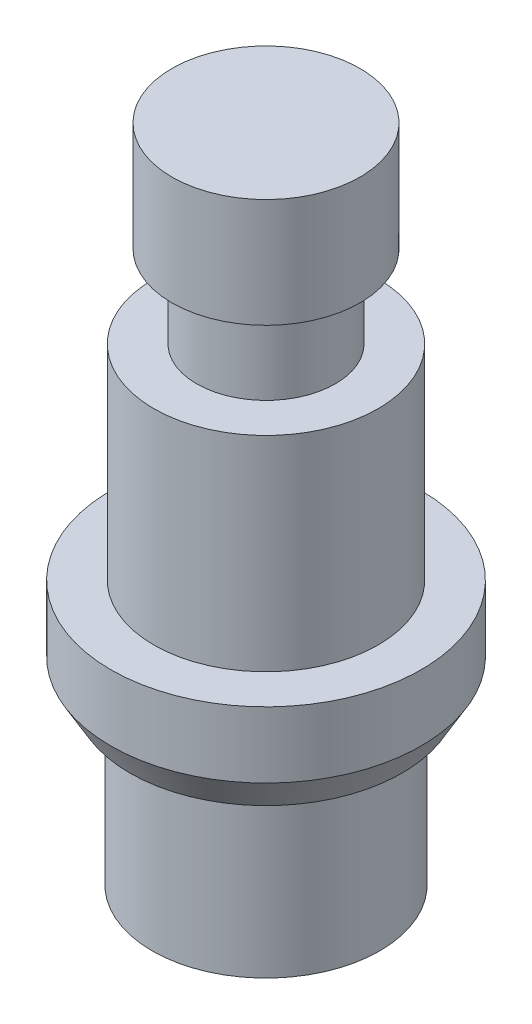
from build123d import *

# Parameters (mm, degrees)
SKETCH1_R           = 4.7
BOSS_EXTRUDE1_DEPTH = 20
SKETCH2_OUTSIDE_W   = 16.202
SKETCH2_OUTSIDE_H   = 16.202
SKETCH2_OUTSIDE_R   = 3.45
CUT_EXTRUDE1_DEPTH  = 5
SKETCH4_OUTSIDE_W   = 16.202
SKETCH4_OUTSIDE_H   = 16.202
SKETCH4_OUTSIDE_R   = 3.4
CUT_EXTRUDE2_DEPTH  = 12
SKETCH5_OUTSIDE_W   = 16.202
SKETCH5_OUTSIDE_H   = 16.202
SKETCH5_OUTSIDE_R   = 2.85
CUT_EXTRUDE3_DEPTH  = 3.3
SKETCH7_OUTSIDE_W   = 16.202
SKETCH7_OUTSIDE_H   = 16.202
SKETCH7_OUTSIDE_R   = 2.1
CUT_EXTRUDE4_DEPTH  = 2.5
CHAMFER1_SIZE       = 1
CHAMFER1_SIZE2      = 0.577350269


with BuildPart() as part:
    # Sketch1 → Boss-Extrude1 (new body)
    with BuildSketch(Plane(origin=(0, 0, 0), x_dir=(1, 0, 0), z_dir=(0, 1, 0))):
        Circle(SKETCH1_R)
    extrude(amount=BOSS_EXTRUDE1_DEPTH)

    # Sketch2 outside → Cut-Extrude1 (cut)
    with BuildSketch(Plane.XZ):
        Rectangle(SKETCH2_OUTSIDE_W, SKETCH2_OUTSIDE_H)
        Circle(SKETCH2_OUTSIDE_R, mode=Mode.SUBTRACT)
    extrude(amount=-CUT_EXTRUDE1_DEPTH, mode=Mode.SUBTRACT)

    # Sketch4 outside → Cut-Extrude2 (cut)
    with BuildSketch(Plane(origin=(0, 20, 0), x_dir=(1, 0, 0), z_dir=(0, 1, 0))):
        Rectangle(SKETCH4_OUTSIDE_W, SKETCH4_OUTSIDE_H)
        Circle(SKETCH4_OUTSIDE_R, mode=Mode.SUBTRACT)
    extrude(amount=-CUT_EXTRUDE2_DEPTH, mode=Mode.SUBTRACT)

    # Sketch5 outside → Cut-Extrude3 (cut)
    with BuildSketch(Plane(origin=(0, 20, 0), x_dir=(1, 0, 0), z_dir=(0, 1, 0))):
        Rectangle(SKETCH5_OUTSIDE_W, SKETCH5_OUTSIDE_H)
        Circle(SKETCH5_OUTSIDE_R, mode=Mode.SUBTRACT)
    extrude(amount=-CUT_EXTRUDE3_DEPTH, mode=Mode.SUBTRACT)

    # Sketch7 outside → Cut-Extrude4 (cut)
    with BuildSketch(Plane(origin=(0, 16.7, 0), x_dir=(1, 0, 0), z_dir=(0, 1, 0))):
        Rectangle(SKETCH7_OUTSIDE_W, SKETCH7_OUTSIDE_H)
        Circle(SKETCH7_OUTSIDE_R, mode=Mode.SUBTRACT)
    extrude(amount=-CUT_EXTRUDE4_DEPTH, mode=Mode.SUBTRACT)

    # Chamfer1
    chamfer1_edges = [part.edges().sort_by_distance(p)[0] for p in [
        (-4.7, 5, 0),
    ]]
    chamfer1_side = [part.faces().sort_by_distance(p)[0] for p in [
        (-4.7, 6.5, 0),
    ]]
    chamfer(chamfer1_edges, length=CHAMFER1_SIZE, length2=CHAMFER1_SIZE2, reference=chamfer1_side[0])


solid = part.part
